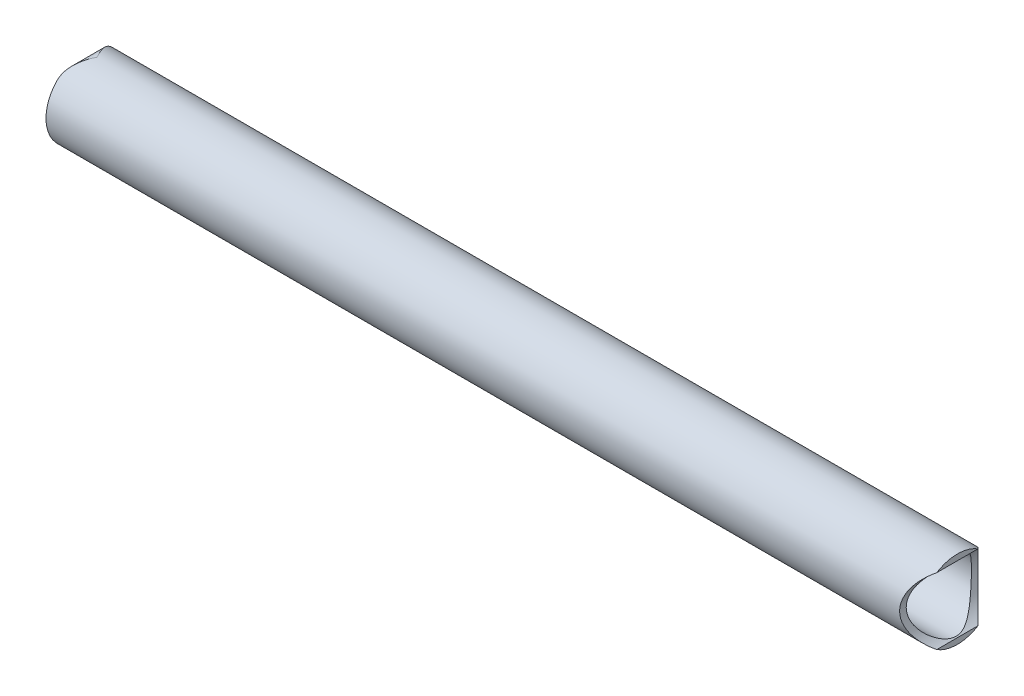
from build123d import *

# Parameters (mm, degrees)
SKETCH1_R               = 21.082
SKETCH1_R_2             = 17.526
BOSS_EXTRUDE1_DEPTH     = 469.10625
CUT_EXTRUDE1_DEPTH      = 22.082
CUT_EXTRUDE1_DEPTH_BACK = 22.082
SKETCH3_R               = 21.082
CUT_EXTRUDE2_DEPTH      = 22.0820001
CUT_EXTRUDE2_DEPTH_BACK = 22.0820001


with BuildPart() as part:
    # Sketch1 → Boss-Extrude1 (new body)
    with BuildSketch(Plane(origin=(0, 0, 0), x_dir=(0, 0, -1), z_dir=(1, 0, 0))):
        Circle(SKETCH1_R)
        Circle(SKETCH1_R_2, mode=Mode.SUBTRACT)
    extrude(amount=BOSS_EXTRUDE1_DEPTH)

    # Sketch2 → Cut-Extrude1 (cut, two sides)
    with BuildSketch(Plane.XY) as cut_extrude1_sk:
        with BuildLine():
            Line((0, 21.082), (0, 14.732))
            ThreePointArc((0, 14.732), (1.859871939, 19.222128061), (6.35, 21.082))
            Line((6.35, 21.082), (0, 21.082))
        make_face()
    extrude(amount=CUT_EXTRUDE1_DEPTH, mode=Mode.SUBTRACT)
    extrude(cut_extrude1_sk.sketch, amount=-CUT_EXTRUDE1_DEPTH_BACK, mode=Mode.SUBTRACT)

    # Sketch3 → Cut-Extrude2 (cut, two sides)
    with BuildSketch(Plane.XY) as cut_extrude2_sk:
        with Locations((480.21875, 0)):
            Circle(SKETCH3_R)
    extrude(amount=CUT_EXTRUDE2_DEPTH, mode=Mode.SUBTRACT)
    extrude(cut_extrude2_sk.sketch, amount=-CUT_EXTRUDE2_DEPTH_BACK, mode=Mode.SUBTRACT)


solid = part.part
